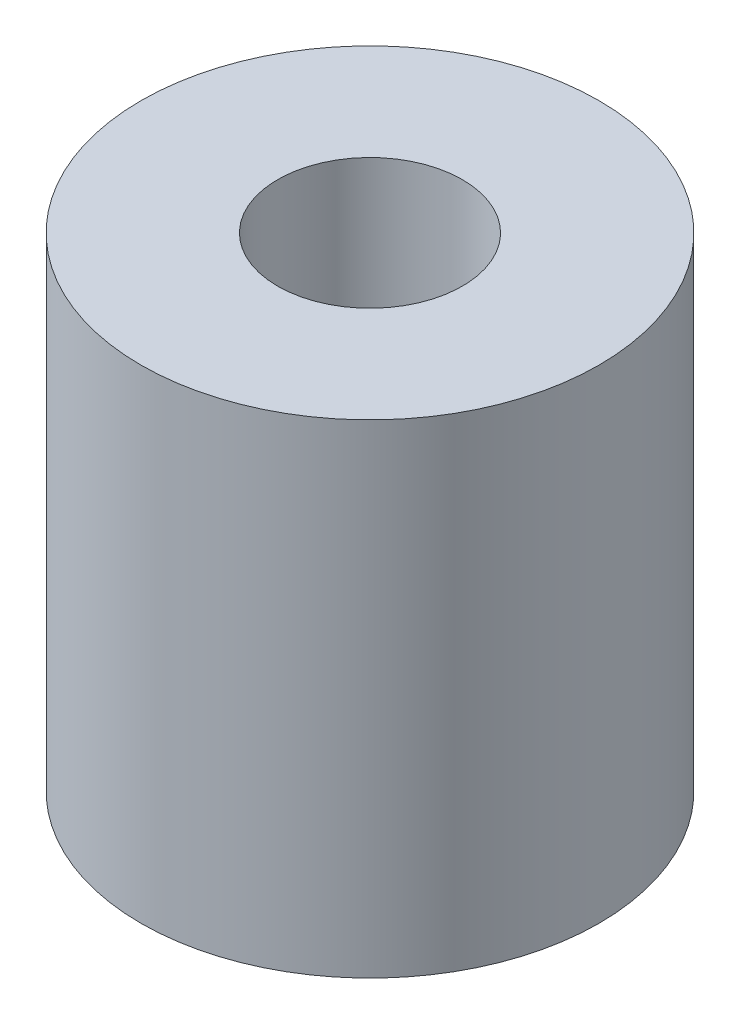
from build123d import *

# Parameters (mm, degrees)
SKETCH1_R           = 7.9375
SKETCH1_R_2         = 3.2004
BOSS_EXTRUDE1_DEPTH = 16.755


with BuildPart() as part:
    # Sketch1 → Boss-Extrude1 (new body)
    with BuildSketch(Plane(origin=(0, 0, 0), x_dir=(1, 0, 0), z_dir=(0, 1, 0))):
        Circle(SKETCH1_R)
        Circle(SKETCH1_R_2, mode=Mode.SUBTRACT)
    extrude(amount=BOSS_EXTRUDE1_DEPTH)


solid = part.part
